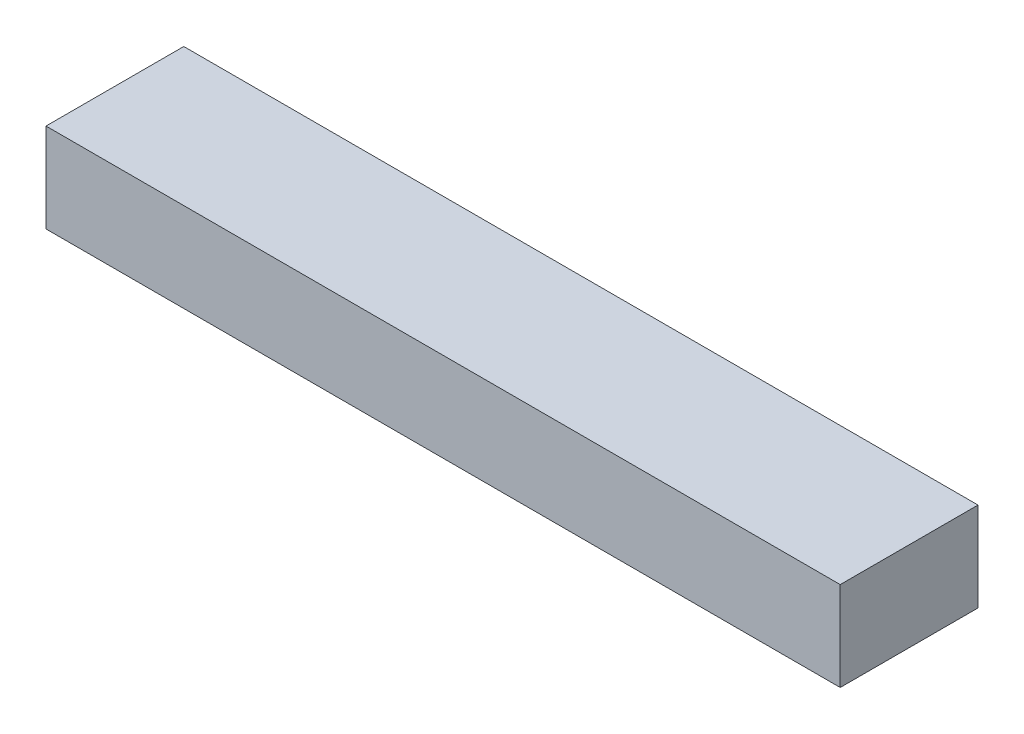
from build123d import *

# Parameters (mm, degrees)
SKETCH1_W           = 98
SKETCH1_H           = 17
BOSS_EXTRUDE1_DEPTH = 11


with BuildPart() as part:
    # Sketch1 → Boss-Extrude1 (new body)
    with BuildSketch(Plane(origin=(0, 0, 0), x_dir=(1, 0, 0), z_dir=(0, 1, 0))):
        with Locations((-49, -8.5)):
            Rectangle(SKETCH1_W, SKETCH1_H)
    extrude(amount=BOSS_EXTRUDE1_DEPTH)


solid = part.part
